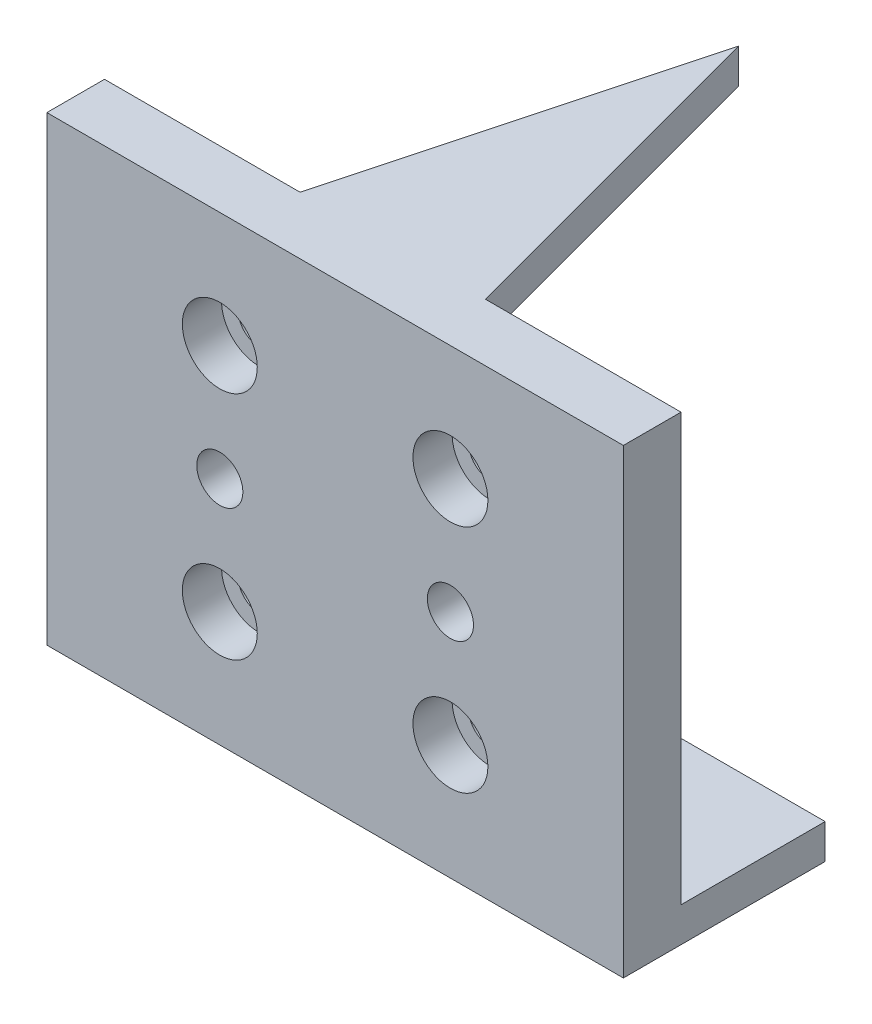
from build123d import *

# Parameters (mm, degrees)
SKIZZE1_W                                            = 50
SKIZZE1_H                                            = 40
AUFSATZ_LINEAR_AUSTRAGEN1_DEPTH                      = 5
AUFSATZ_LINEAR_AUSTRAGEN2_DEPTH                      = 3
STIRNSENKUNG_F_R_M3_ZYLINDERSCHRAUBE_MIT_D           = 3.6
STIRNSENKUNG_F_R_M3_ZYLINDERSCHRAUBE_MIT_DEPTH       = 5
STIRNSENKUNG_F_R_M3_ZYLINDERSCHRAUBE_MIT_CBORE_D     = 6.5
STIRNSENKUNG_F_R_M3_ZYLINDERSCHRAUBE_MIT_CBORE_DEPTH = 3.4
SKIZZE6_R                                            = 2
SCHNITT_LINEAR_AUSTRAGEN1_DEPTH                      = 36
SKIZZE7_W                                            = 50
SKIZZE7_H                                            = 3
AUFSATZ_LINEAR_AUSTRAGEN3_DEPTH                      = 12.5


with BuildPart() as part:
    # Skizze1 → Aufsatz-Linear austragen1 (new body)
    with BuildSketch(Plane.XY):
        with Locations((25, -20)):
            Rectangle(SKIZZE1_W, SKIZZE1_H)
    extrude(amount=AUFSATZ_LINEAR_AUSTRAGEN1_DEPTH)

    # Skizze2 → Aufsatz-Linear austragen2 (add)
    with BuildSketch(Plane(origin=(0, 0, 0), x_dir=(1, 0, 0), z_dir=(0, 1, 0))):
        Polygon((25, 30), (16.961524227, 0), (33.038475773, 0), align=None)
    extrude(amount=-AUFSATZ_LINEAR_AUSTRAGEN2_DEPTH)

    # Stirnsenkung für M3 Zylinderschraube mit Innensechskant1
    with Locations(Plane.XY.offset(5)):
        with Locations((15, -10), (35, -10), (35, -30), (15, -30)):
            CounterBoreHole(STIRNSENKUNG_F_R_M3_ZYLINDERSCHRAUBE_MIT_D / 2, STIRNSENKUNG_F_R_M3_ZYLINDERSCHRAUBE_MIT_CBORE_D / 2, STIRNSENKUNG_F_R_M3_ZYLINDERSCHRAUBE_MIT_CBORE_DEPTH, depth=STIRNSENKUNG_F_R_M3_ZYLINDERSCHRAUBE_MIT_DEPTH)

    # Skizze6 → Schnitt-Linear austragen1 (cut, through all)
    with BuildSketch(Plane.XY.offset(5)):
        with Locations((15, -20)):
            Circle(SKIZZE6_R)
        with Locations((35, -20)):
            Circle(SKIZZE6_R)
    extrude(amount=-SCHNITT_LINEAR_AUSTRAGEN1_DEPTH, mode=Mode.SUBTRACT)

    # Skizze7 → Aufsatz-Linear austragen3 (add)
    with BuildSketch(Plane(origin=(0, 0, 0), x_dir=(-1, 0, 0), z_dir=(0, 0, -1))):
        with Locations((-25, -38.5)):
            Rectangle(SKIZZE7_W, SKIZZE7_H)
    extrude(amount=AUFSATZ_LINEAR_AUSTRAGEN3_DEPTH)


solid = part.part
